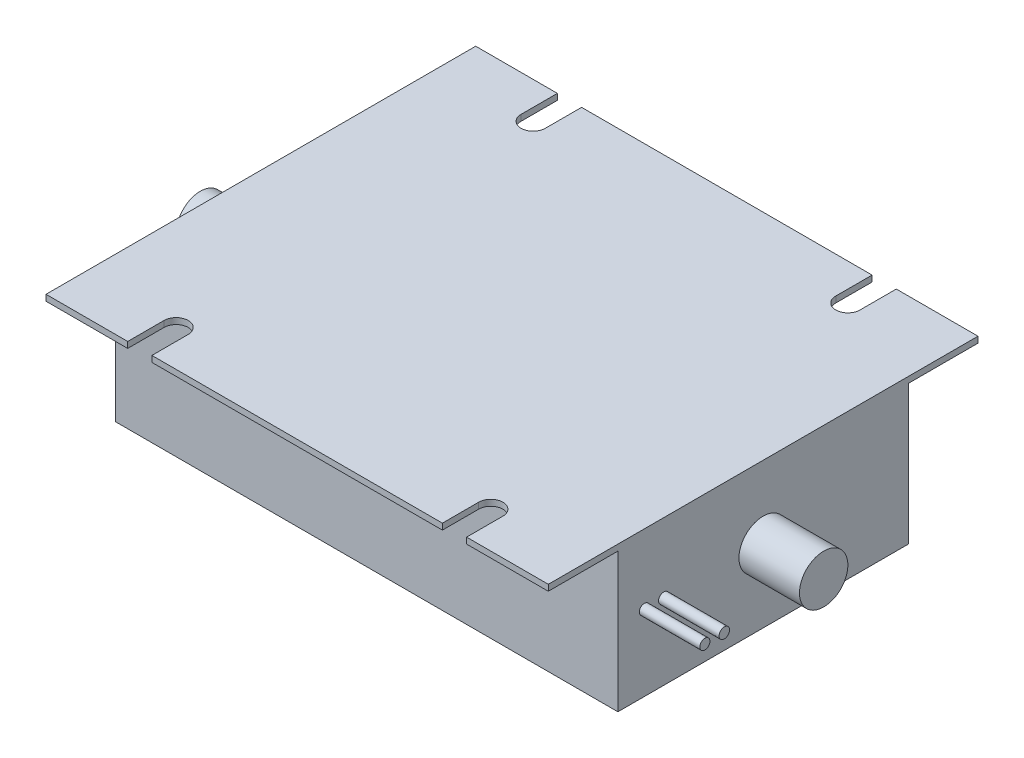
from build123d import *

# Parameters (mm, degrees)
SKETCH_1_W            = 83
SKETCH_1_H            = 48
EXTRUDE_1_DEPTH       = 24
SKETCH_21_W           = 83
SKETCH_21_H           = 1
EXTRUDE_2_DEPTH       = 35.5
CUT_EXTRUDE_20_DEPTH  = 60.653164208
MIRROR_2_COPY_1_DEPTH = 60.653164208
MIRROR_2_COPY_2_DEPTH = 60.653164208
SKETCH_27_R           = 4
EXTRUDE_4_DEPTH       = 10
SKETCH_28_R           = 0.835314329
SKETCH_28_R_2         = 0.866649433
EXTRUDE_5_DEPTH       = 10


with BuildPart() as part:
    # 草圖1 → 填料-伸長1 (new body)
    with BuildSketch(Plane(origin=(0, 18, 0), x_dir=(1, 0, 0), z_dir=(0, 1, 0))):
        Rectangle(SKETCH_1_W, SKETCH_1_H)
    extrude(amount=-EXTRUDE_1_DEPTH)

    # 草圖21 → 填料-伸長2 (add, symmetric)
    with BuildSketch(Plane(origin=(0, 0, 0), x_dir=(-1, 0, 0), z_dir=(0, 0, -1))):
        with Locations((0, 17.5)):
            Rectangle(SKETCH_21_W, SKETCH_21_H)
    extrude(amount=EXTRUDE_2_DEPTH, both=True)

    # 草圖22 → 除料-伸長20 (cut, through all)
    with BuildSketch(Plane(origin=(0, 18, 0), x_dir=(-1, 0, 0), z_dir=(0, 1, 0))):
        with BuildLine():
            Line((-28, -29.5), (-28, -35.5))
            Line((-28, -35.5), (-24, -35.5))
            Line((-24, -35.5), (-24, -29.5))
            ThreePointArc((-24, -29.5), (-26, -27.5), (-28, -29.5))
        make_face()
    cut_extrude_20 = extrude(amount=-CUT_EXTRUDE_20_DEPTH, mode=Mode.SUBTRACT)

    # 鏡射1: 除料-伸長20 across plane
    add(cut_extrude_20.mirror(Plane(origin=(0, 0, 0), x_dir=(0, 0, 1), z_dir=(1, 0, 0))), mode=Mode.SUBTRACT)

    # 鏡射2 copy 1 sketch → 鏡射2 copy 1 (cut, through all)
    with BuildSketch(Plane(origin=(0, 18, 0), x_dir=(1, 0, 0), z_dir=(0, 1, 0))):
        with BuildLine():
            Line((-28, -29.5), (-28, -35.5))
            Line((-28, -35.5), (-24, -35.5))
            Line((-24, -35.5), (-24, -29.5))
            ThreePointArc((-24, -29.5), (-26, -27.5), (-28, -29.5))
        make_face()
    extrude(amount=-MIRROR_2_COPY_1_DEPTH, mode=Mode.SUBTRACT)

    # 鏡射2 copy 2 sketch → 鏡射2 copy 2 (cut, through all)
    with BuildSketch(Plane(origin=(0, 18, 0), x_dir=(-1, 0, 0), z_dir=(0, 1, 0))):
        with BuildLine():
            Line((-28, 29.5), (-28, 35.5))
            Line((-28, 35.5), (-24, 35.5))
            Line((-24, 35.5), (-24, 29.5))
            ThreePointArc((-24, 29.5), (-26, 27.5), (-28, 29.5))
        make_face()
    extrude(amount=-MIRROR_2_COPY_2_DEPTH, mode=Mode.SUBTRACT)

    # 草圖27 → 填料-伸長4 (add)
    with BuildSketch(Plane.ZY.offset(41.5)):
        with Locations((0, 6)):
            Circle(SKETCH_27_R)
    extrude_4 = extrude(amount=EXTRUDE_4_DEPTH)

    # 鏡射3: 填料-伸長4 across plane
    add(extrude_4.mirror(Plane(origin=(0, 0, 0), x_dir=(0, 0, 1), z_dir=(1, 0, 0))))

    # 草圖28 → 填料-伸長5 (add)
    with BuildSketch(Plane(origin=(41.5, 0, 0), x_dir=(0, 0, -1), z_dir=(1, 0, 0))):
        with Locations((-19.628552742, 6.499481813)):
            Circle(SKETCH_28_R)
        with Locations((-16.419283225, 6.499481813)):
            Circle(SKETCH_28_R_2)
    extrude(amount=EXTRUDE_5_DEPTH)


solid = part.part
